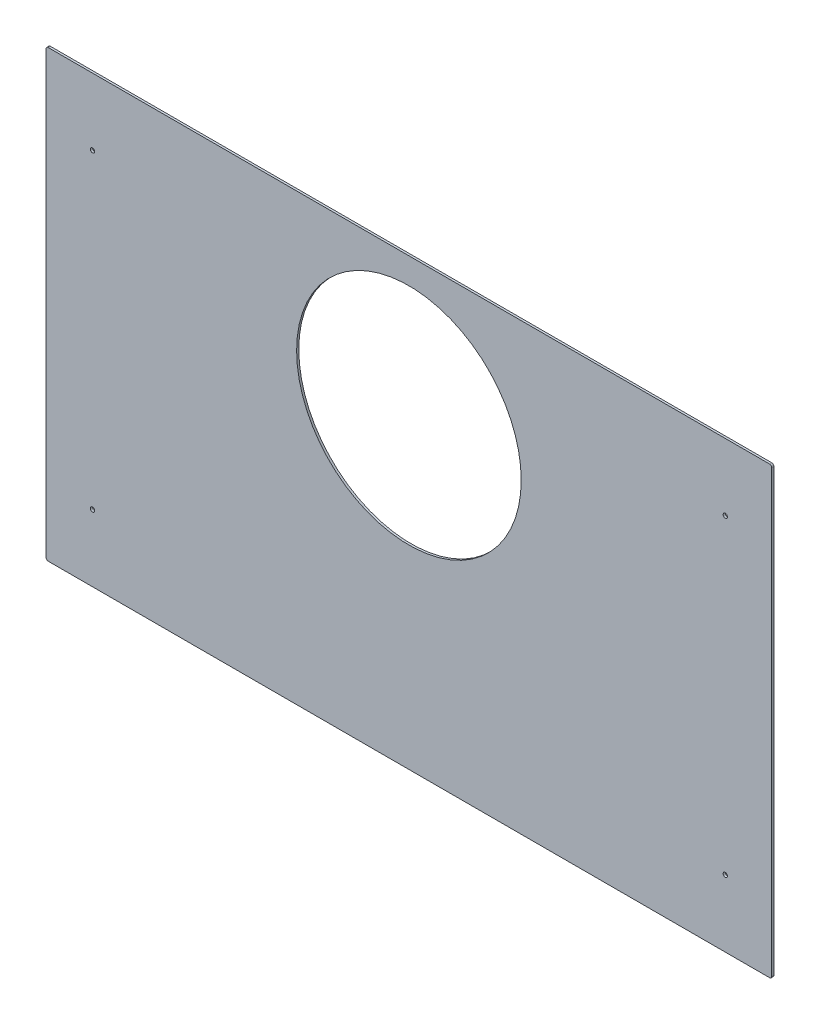
from build123d import *

# Parameters (mm, degrees)
SKETCH1_W                   = 1066.8
SKETCH1_H                   = 654.05
SKETCH1_R                   = 165.1
BOSS_EXTRUDE1_DEPTH         = 3.175
F_1_4_0_25_DIAMETER_HOLE2_D = 6.35
FILLET1_R                   = 3.175


with BuildPart() as part:
    # Sketch1 → Boss-Extrude1 (new body)
    with BuildSketch(Plane.XY):
        with Locations((533.4, 327.025)):
            Rectangle(SKETCH1_W, SKETCH1_H)
        with Locations((533.4, 450.85)):
            Circle(SKETCH1_R, mode=Mode.SUBTRACT)
    extrude(amount=BOSS_EXTRUDE1_DEPTH)

    # 1/4 (0.25) Diameter Hole2 (through all)
    with Locations(Plane(origin=(0, 0, 0), x_dir=(-1, 0, 0), z_dir=(0, 0, -1))):
        with Locations((-998.5375, 555.625), (-998.5375, 98.425), (-68.2625, 98.425), (-68.2625, 555.625)):
            Hole(F_1_4_0_25_DIAMETER_HOLE2_D / 2)

    # Fillet1
    fillet1_edges = [part.edges().sort_by_distance(p)[0] for p in [
        (0, 654.05, 1.5875),
        (1066.8, 654.05, 1.5875),
        (1066.8, 0, 1.5875),
        (0, 0, 1.5875),
    ]]
    fillet(fillet1_edges, radius=FILLET1_R)


solid = part.part
